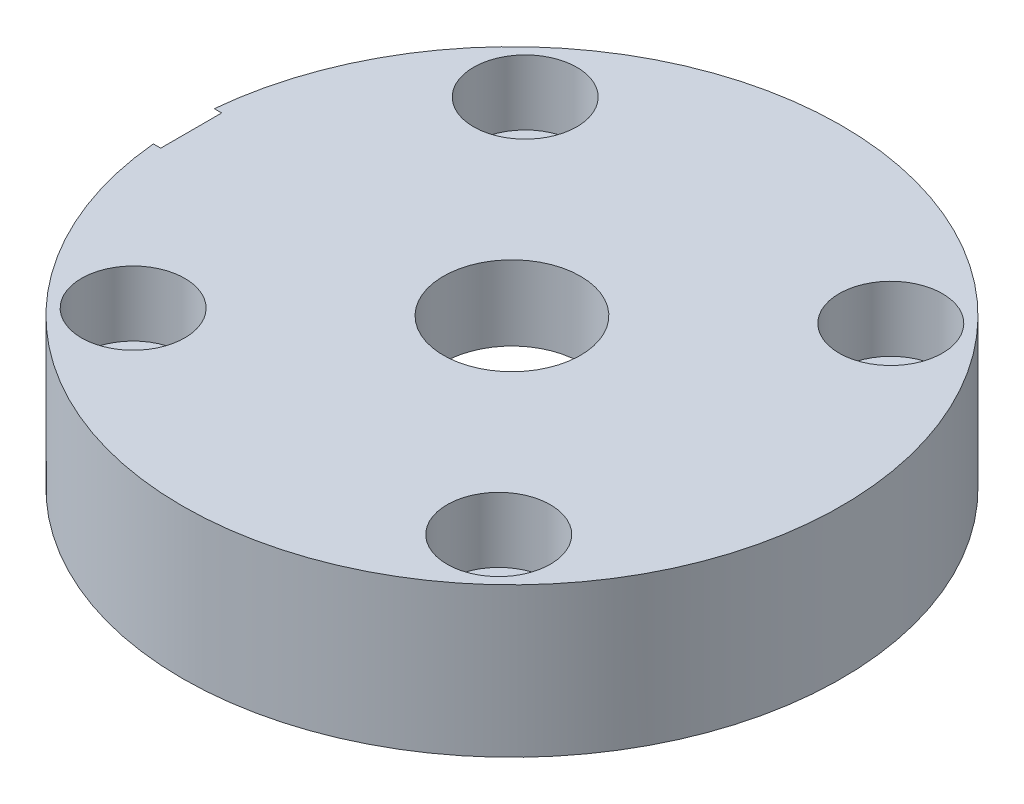
from build123d import *

# Parameters (mm, degrees)
SKETCH1_W         = 19.05
SKETCH1_H         = 8.636
HOLE1_D           = 3.9624
HOLE1_CBORE_D     = 5.969
HOLE1_CBORE_DEPTH = 3.7592
HOLE2_D           = 3.9624
HOLE2_CBORE_D     = 5.969
HOLE2_CBORE_DEPTH = 3.7592
HOLE3_D           = 3.9624
HOLE3_CBORE_D     = 5.969
HOLE3_CBORE_DEPTH = 3.7592
HOLE4_D           = 3.9624
HOLE4_CBORE_D     = 5.969
HOLE4_CBORE_DEPTH = 3.7592
HOLE5_D           = 7.9248
SKETCH13_W        = 10.3124
SKETCH13_H        = 4.318
HOLE6_D           = 3.4544
HOLE6_DEPTH       = 4.318
HOLE7_D           = 3.4544
HOLE7_DEPTH       = 4.318
HOLE8_D           = 3.4544
HOLE8_DEPTH       = 4.318
HOLE9_D           = 3.4544
HOLE9_DEPTH       = 4.318


with BuildPart() as part:
    # Sketch1 → Revolve1 (revolve)
    with BuildSketch(Plane.XY):
        with Locations((9.525, 4.318)):
            Rectangle(SKETCH1_W, SKETCH1_H)
    revolve(axis=Axis((0, 0, 0), (0, 1, 0)))

    # Sketch2 → Cut-Revolve1 (revolve, cut)
    with BuildSketch(Plane.XY):
        Polygon((-19.05, 5.08), (-19.05, 9.04875), (-18.542, 9.04875), (-18.542, 7.493), (-18.11274, 7.06374), (-7.874, 7.06374), (-6.728687177, 5.08), align=None)
    revolve(axis=Axis((-6.728687177, 5.08, 0), (-1, 0, 0)), mode=Mode.SUBTRACT)

    # Hole1 (through all)
    with Locations(Plane(origin=(0, 8.636, 0), x_dir=(1, 0, 0), z_dir=(0, 1, 0))):
        with Locations((-10.566882591, 11.331594253)):
            CounterBoreHole(HOLE1_D / 2, HOLE1_CBORE_D / 2, HOLE1_CBORE_DEPTH)

    # Hole2 (through all)
    with Locations(Plane(origin=(0, 8.636, 0), x_dir=(1, 0, 0), z_dir=(0, 1, 0))):
        with Locations((-11.331594253, -10.566882591)):
            CounterBoreHole(HOLE2_D / 2, HOLE2_CBORE_D / 2, HOLE2_CBORE_DEPTH)

    # Hole3 (through all)
    with Locations(Plane(origin=(0, 8.636, 0), x_dir=(1, 0, 0), z_dir=(0, 1, 0))):
        with Locations((10.566882591, -11.331594253)):
            CounterBoreHole(HOLE3_D / 2, HOLE3_CBORE_D / 2, HOLE3_CBORE_DEPTH)

    # Hole4 (through all)
    with Locations(Plane(origin=(0, 8.636, 0), x_dir=(1, 0, 0), z_dir=(0, 1, 0))):
        with Locations((11.331594253, 10.566882591)):
            CounterBoreHole(HOLE4_D / 2, HOLE4_CBORE_D / 2, HOLE4_CBORE_DEPTH)

    # Hole5 (through all)
    with Locations(Plane(origin=(0, 0, 0), x_dir=(-1, 0, 0), z_dir=(0, -1, 0))):
        with Locations((0, 0)):
            Hole(HOLE5_D / 2)

    # Sketch13 → Cut-Revolve2 (revolve, cut)
    with BuildSketch(Plane.XY):
        with Locations((5.1562, 2.159)):
            Rectangle(SKETCH13_W, SKETCH13_H)
    revolve(axis=Axis((0, 0, 0), (0, 1, 0)), mode=Mode.SUBTRACT)

    # Hole6
    with Locations(Plane(origin=(0, 0, 0), x_dir=(-1, 0, 0), z_dir=(0, -1, 0))):
        with Locations((4.140591399, -14.930490242)):
            Hole(HOLE6_D / 2, depth=HOLE6_DEPTH)

    # Hole7
    with Locations(Plane(origin=(0, 0, 0), x_dir=(-1, 0, 0), z_dir=(0, -1, 0))):
        with Locations((-14.930490242, -4.140591399)):
            Hole(HOLE7_D / 2, depth=HOLE7_DEPTH)

    # Hole8
    with Locations(Plane(origin=(0, 0, 0), x_dir=(-1, 0, 0), z_dir=(0, -1, 0))):
        with Locations((-4.140591399, 14.930490242)):
            Hole(HOLE8_D / 2, depth=HOLE8_DEPTH)

    # Hole9
    with Locations(Plane(origin=(0, 0, 0), x_dir=(-1, 0, 0), z_dir=(0, -1, 0))):
        with Locations((14.930490242, 4.140591399)):
            Hole(HOLE9_D / 2, depth=HOLE9_DEPTH)


solid = part.part
